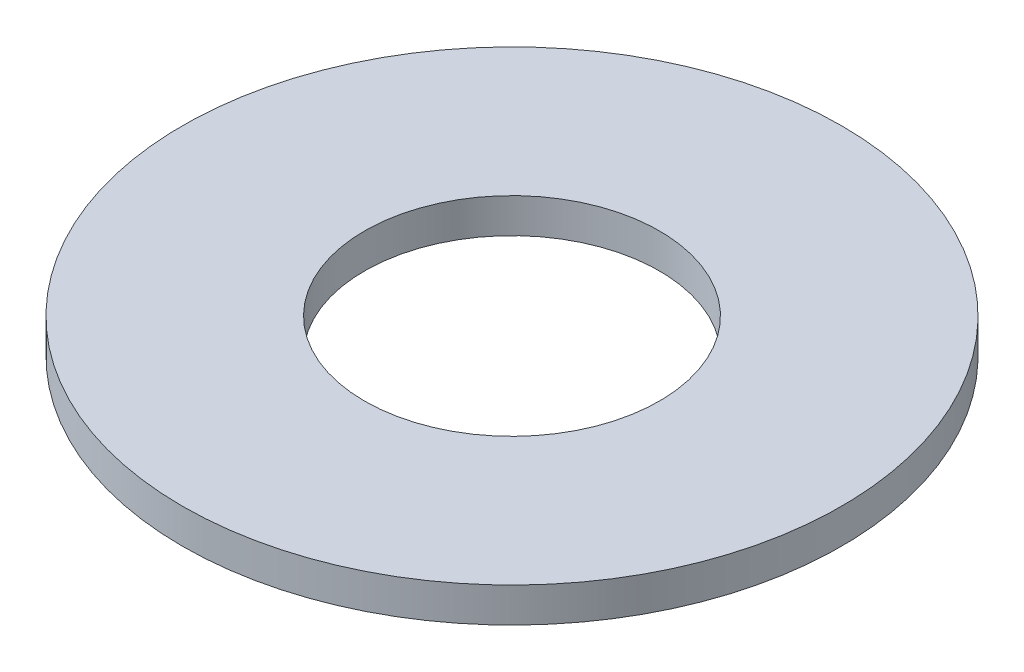
from build123d import *

# Parameters (mm, degrees)
SKETCH1_R           = 4.826
SKETCH1_R_2         = 2.159
BOSS_EXTRUDE1_DEPTH = 0.508


with BuildPart() as part:
    # Sketch1 → Boss-Extrude1 (new body)
    with BuildSketch(Plane(origin=(0, 0, 0), x_dir=(1, 0, 0), z_dir=(0, 1, 0))):
        with Locations(Location((0, 0, 0), (0, 0, 270))):  # turned: the seam where the file's is
            Circle(SKETCH1_R)
        with Locations(Location((0, 0, 0), (0, 0, 270))):  # turned: the seam where the file's is
            Circle(SKETCH1_R_2, mode=Mode.SUBTRACT)
    extrude(amount=BOSS_EXTRUDE1_DEPTH)


solid = part.part
